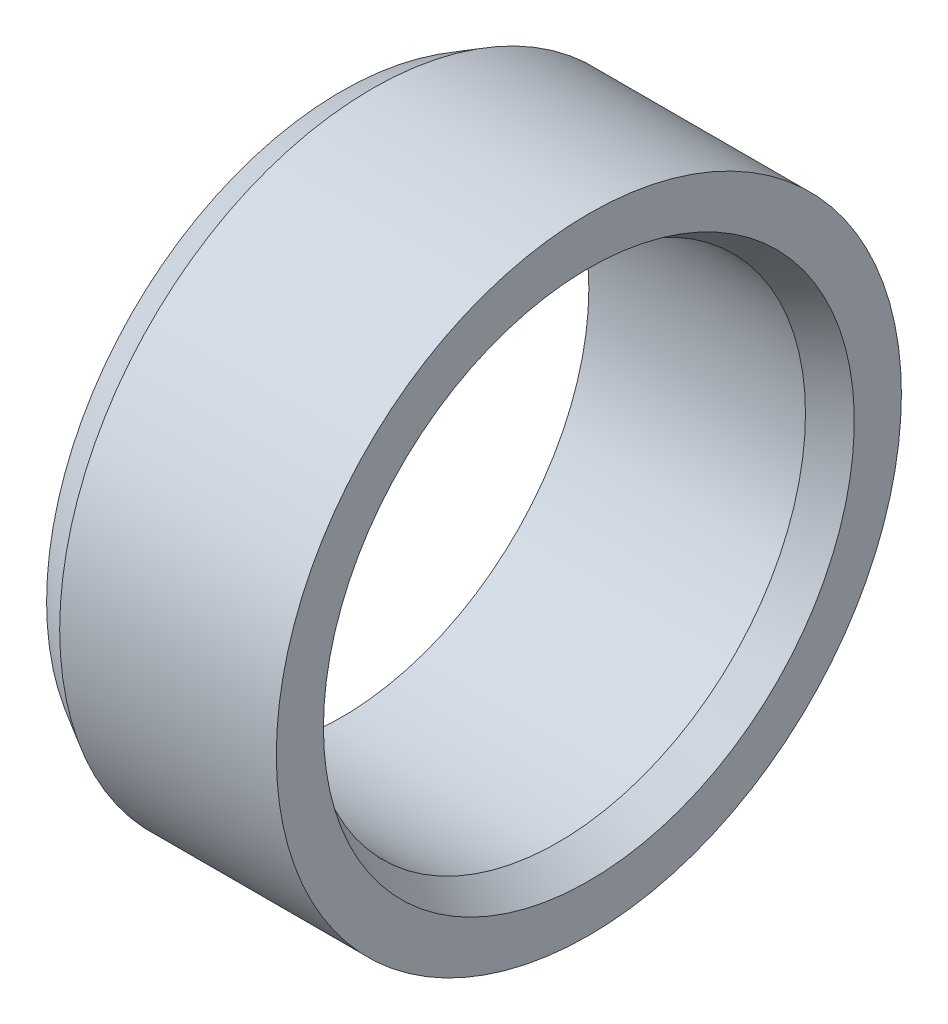
from build123d import *


with BuildPart() as part:
    # Skizze1 → Rotation1 (revolve)
    with BuildSketch(Plane(origin=(0, 0, 0), x_dir=(1, 0, 0), z_dir=(0, 1, 0))):
        Polygon((-1.5, 5.05), (2, 5.05), (2, 4.288675135), (1.5, 4), (-2, 4), (-2, 4.761324865), align=None)
    revolve(axis=Axis((-2, 0, 0), (1, 0, 0)))


solid = part.part
